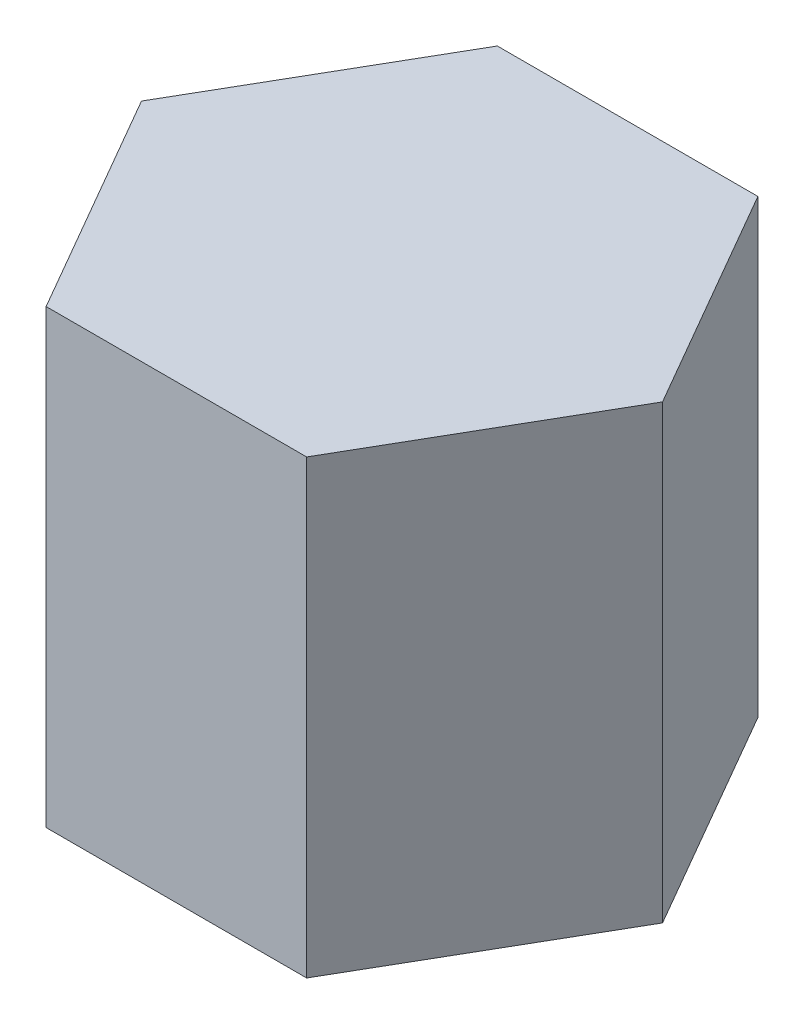
from build123d import *

# Parameters (mm, degrees)
EXTRUDE_1_DEPTH = 50


with BuildPart() as part:
    # 草圖1 → 填料-伸長1 (new body)
    with BuildSketch(Plane(origin=(0, 0, 0), x_dir=(1, 0, 0), z_dir=(0, 1, 0))):
        Polygon((28.867513459, 0), (14.43375673, 25), (-14.43375673, 25), (-28.867513459, 0), (-14.43375673, -25), (14.43375673, -25), align=None)
    extrude(amount=EXTRUDE_1_DEPTH)


solid = part.part
